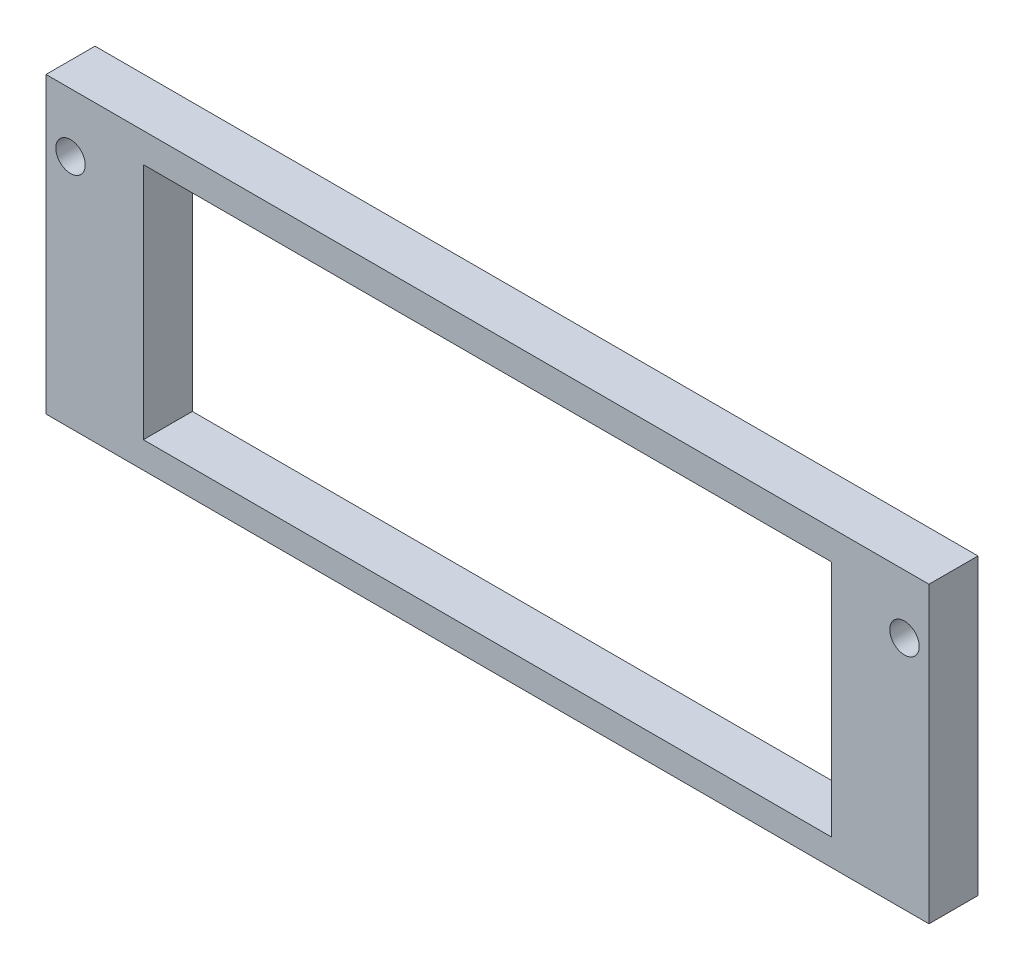
from build123d import *

# Parameters (mm, degrees)
ESBO_O1_W                = 90.06
ESBO_O1_H                = 30
RESSALTO_EXTRUS_O1_DEPTH = 5
ESBO_O2_W                = 70.2
ESBO_O2_H                = 24.3
CORTE_EXTRUS_O1_DEPTH    = 6
ESBO_O4_R                = 1.5
CORTE_EXTRUS_O2_DEPTH    = 10


with BuildPart() as part:
    # Esboço1 → Ressalto-extrusão1 (new body)
    with BuildSketch(Plane.XY):
        with Locations((19.809040323, 1.862332774)):
            Rectangle(ESBO_O1_W, ESBO_O1_H)
    extrude(amount=RESSALTO_EXTRUS_O1_DEPTH)

    # Esboço2 → Corte-extrusão1 (cut, through all)
    with BuildSketch(Plane(origin=(0, 0, 0), x_dir=(-1, 0, 0), z_dir=(0, 0, -1))):
        with Locations((-19.809040323, 1.712332774)):
            Rectangle(ESBO_O2_W, ESBO_O2_H)
    extrude(amount=-CORTE_EXTRUS_O1_DEPTH, mode=Mode.SUBTRACT)

    # Esboço4 → Corte-extrusão2 (cut)
    with BuildSketch(Plane(origin=(0, 0, 0), x_dir=(-1, 0, 0), z_dir=(0, 0, -1))):
        with Locations((22.720959677, 10.862332774)):
            Circle(ESBO_O4_R)
        with Locations((-62.339040323, 10.862332774)):
            Circle(ESBO_O4_R)
    extrude(amount=-CORTE_EXTRUS_O2_DEPTH, mode=Mode.SUBTRACT)


solid = part.part
